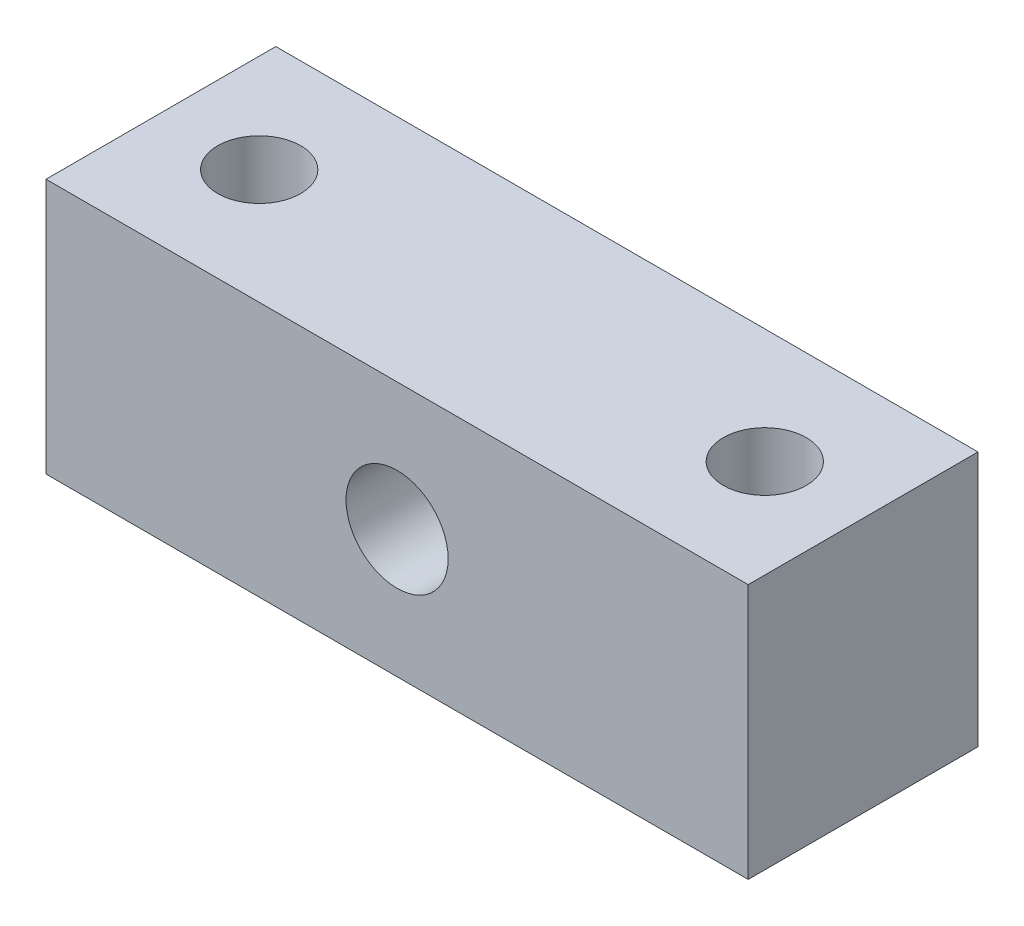
from build123d import *

# Parameters (mm, degrees)
SKETCH_1_W              = 55
SKETCH_1_H              = 20
EXTRUDE_1_DEPTH         = 18
SKETCH_2_R              = 4
CUT_EXTRUDE_1_DEPTH     = 18
HOLE_WIZARD_6_5_6_5_1_D = 6.5


with BuildPart() as part:
    # Эскиз1 → Бобышка-Вытянуть1 (new body)
    with BuildSketch(Plane.XY):
        Rectangle(SKETCH_1_W, SKETCH_1_H)
    extrude(amount=EXTRUDE_1_DEPTH)

    # Эскиз2 → Вырез-Вытянуть1 (cut)
    with BuildSketch(Plane.XY.offset(18)):
        Circle(SKETCH_2_R)
    extrude(amount=-CUT_EXTRUDE_1_DEPTH, mode=Mode.SUBTRACT)

    # Диаметр отверстия Ø6.5 (6.5)1 (through all)
    with Locations(Plane(origin=(0, 10, 0), x_dir=(1, 0, 0), z_dir=(0, 1, 0))):
        with Locations((19.8, -9), (-19.8, -9)):
            Hole(HOLE_WIZARD_6_5_6_5_1_D / 2)


solid = part.part
